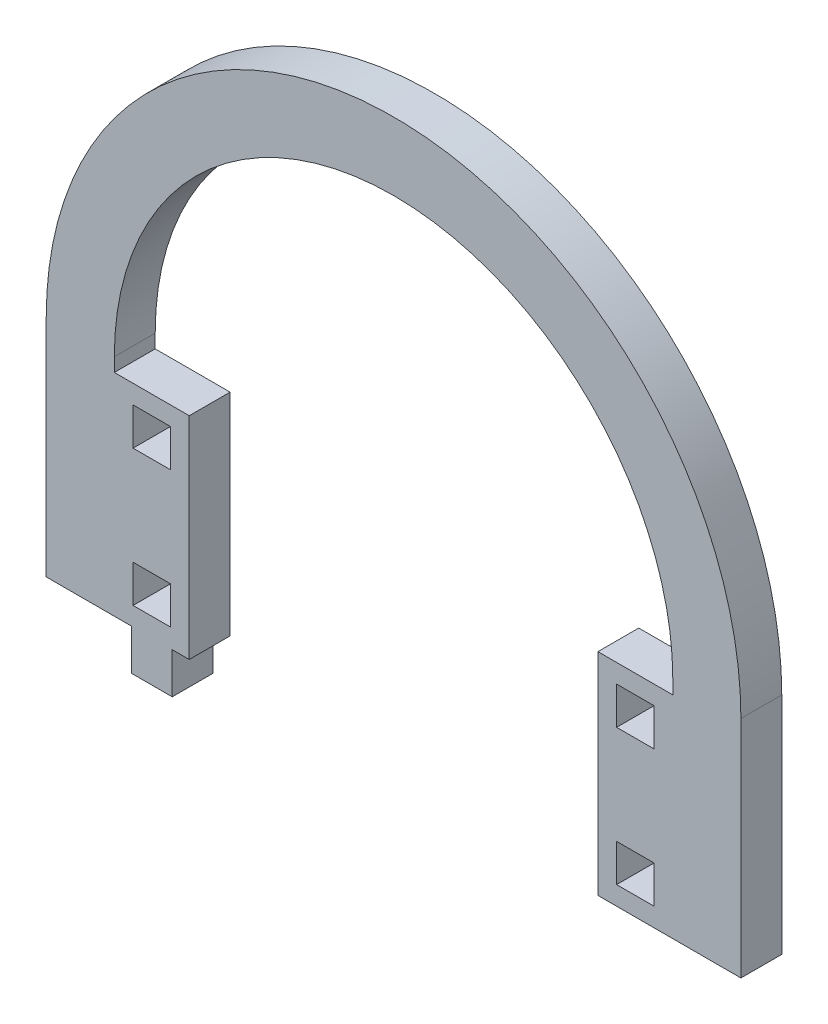
from build123d import *

# Parameters (mm, degrees)
MODEL_W             = 5.5
MODEL_H             = 5.5
BOSS_EXTRUDE1_DEPTH = 6


with BuildPart() as part:
    # Model → Boss-Extrude1 (new body)
    with BuildSketch(Plane.XY):
        with BuildLine():
            Line((3367.68426312, 1328.903027574), (3367.68426312, 1295.903027574))
            Line((3367.68426312, 1295.903027574), (3380.18426312, 1295.903027574))
            Line((3380.18426312, 1295.903027574), (3380.18426312, 1289.903027574))
            Line((3380.18426312, 1289.903027574), (3386.18426312, 1289.903027574))
            Line((3386.18426312, 1289.903027574), (3386.18426312, 1295.903027574))
            Line((3386.18426312, 1295.903027574), (3388.68426312, 1295.903027574))
            Line((3388.68426312, 1295.903027574), (3388.68426312, 1326.903027574))
            Line((3388.68426312, 1326.903027574), (3377.68426312, 1326.903027574))
            Line((3377.68426312, 1326.903027574), (3377.68426312, 1328.903027574))
            ThreePointArc((3377.68426312, 1328.903027574), (3418.68426312, 1369.903027574), (3459.68426312, 1328.903027574))
            Line((3459.68426312, 1328.903027574), (3459.68426312, 1326.903027574))
            Line((3459.68426312, 1326.903027574), (3448.68426312, 1326.903027574))
            Line((3448.68426312, 1326.903027574), (3448.68426312, 1295.903027574))
            Line((3448.68426312, 1295.903027574), (3459.68426312, 1295.903027574))
            Line((3459.68426312, 1295.903027574), (3469.68426312, 1295.903027574))
            Line((3469.68426312, 1295.903027574), (3469.68426312, 1328.903027574))
            ThreePointArc((3469.68426312, 1328.903027574), (3418.68426312, 1379.903027574), (3367.68426312, 1328.903027574))
        make_face()
        with Locations((3454.18426312, 1301.403027574)):
            Rectangle(MODEL_W, MODEL_H, mode=Mode.SUBTRACT)
        with Locations((3454.18426312, 1321.403027574)):
            Rectangle(MODEL_W, MODEL_H, mode=Mode.SUBTRACT)
        with Locations((3383.18426312, 1301.403027574)):
            Rectangle(MODEL_W, MODEL_H, mode=Mode.SUBTRACT)
        with Locations((3383.18426312, 1321.403027574)):
            Rectangle(MODEL_W, MODEL_H, mode=Mode.SUBTRACT)
    extrude(amount=BOSS_EXTRUDE1_DEPTH)


solid = part.part
